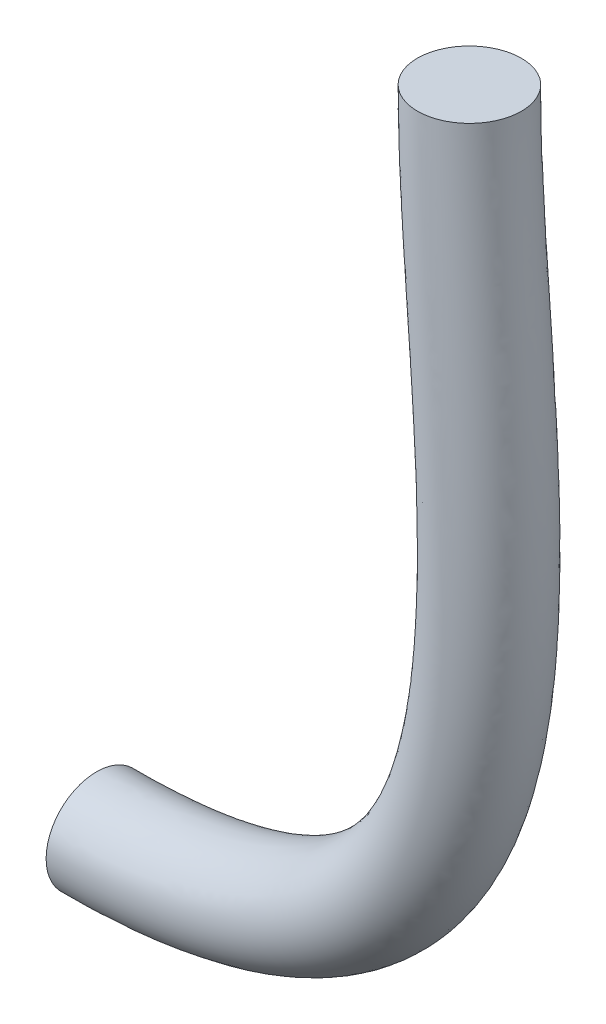
from build123d import *

# Parameters (mm, degrees)
SZKIC1_R = 6.5


with BuildPart() as part:
    # Wyciągnięcie po ścieżce1: sweep along a curve in space
    with BuildLine() as wyci_gni_cie_po_cie_ce1_path:
        add(Edge.make_bspline(
            [(0, 0, 0), (1.183730869, -41.250408072, 1.248488002), (18.195569025, -108.322747625, -0.846469437), (-49.314477253, -108.462748984, -1.326722272)],
            knots=[0, 0, 0, 0, 1, 1, 1, 1], degree=3))
    # Szkic1 → Wyciągnięcie po ścieżce1 (sweep)
    with BuildSketch(Plane(origin=(0, 0, 0), x_dir=(-0.999588886, -0.028661969, 0.000741937), z_dir=(0.028671296, -0.999131379, 0.030239787))):
        Circle(SZKIC1_R)
    sweep(path=wyci_gni_cie_po_cie_ce1_path.line)


solid = part.part
